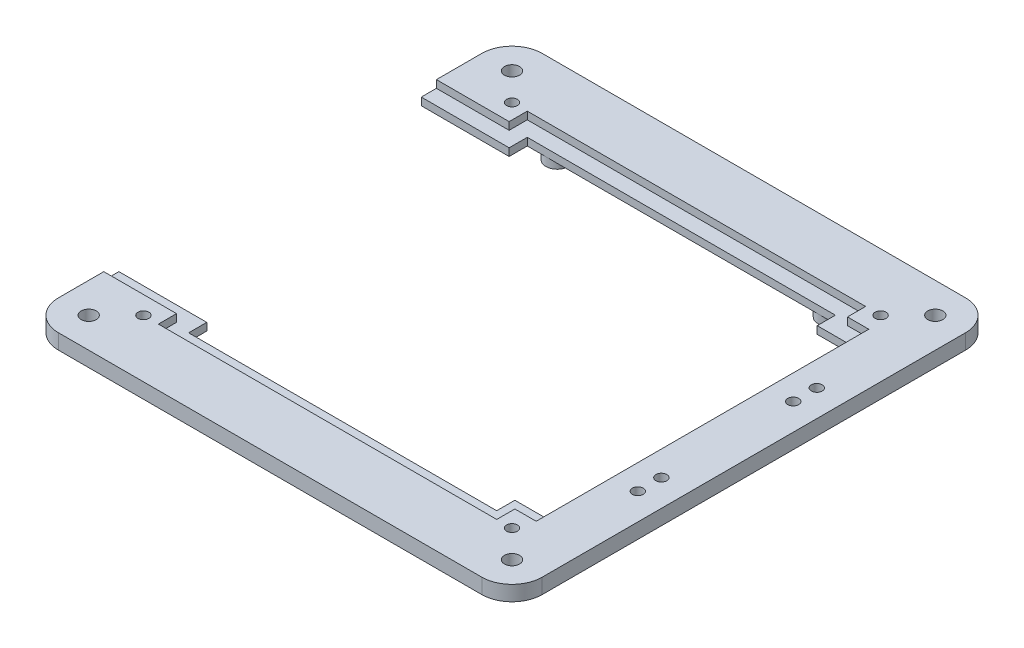
from build123d import *

# Parameters (mm, degrees)
BOSS_EXTRUDE2_DEPTH = 6.35
SKETCH2_R           = 3.175
CUT_EXTRUDE1_DEPTH  = 7.35
SKETCH7_R           = 2.286
CUT_EXTRUDE3_DEPTH  = 12.7
SKETCH8_R           = 2.286
CUT_EXTRUDE4_DEPTH  = 7.35
SKETCH9_W           = 129.404437756
SKETCH9_H           = 7.62
CUT_EXTRUDE5_DEPTH  = 7.35
SKETCH10_R          = 4.826
SKETCH10_R_2        = 2.286
BOSS_EXTRUDE3_DEPTH = 3.81
CUT_EXTRUDE6_DEPTH  = 3.175


with BuildPart() as part:
    # Sketch1 → Boss-Extrude2 (new body)
    with BuildSketch(Plane(origin=(0, 0, 0), x_dir=(1, 0, 0), z_dir=(0, 1, 0))):
        with BuildLine():
            Line((0, 0), (0, 25.4))
            ThreePointArc((0, 25.4), (3.719743879, 34.380256121), (12.7, 38.1))
            Line((12.7, 38.1), (190.5, 38.1))
            ThreePointArc((190.5, 38.1), (199.480256121, 34.380256121), (203.2, 25.4))
            Line((203.2, 25.4), (203.2, -152.4))
            ThreePointArc((203.2, -152.4), (199.480256121, -161.380256121), (190.5, -165.1))
            Line((190.5, -165.1), (12.7, -165.1))
            ThreePointArc((12.7, -165.1), (3.719743879, -161.380256121), (0, -152.4))
            Line((0, -152.4), (0, -127))
            Line((0, -127), (181.61, -127))
            Line((181.61, -127), (181.61, 0))
            Line((181.61, 0), (0, 0))
        make_face()
    extrude(amount=BOSS_EXTRUDE2_DEPTH)

    # Sketch2 → Cut-Extrude1 (cut, through all)
    with BuildSketch(Plane(origin=(0, 6.35, 0), x_dir=(1, 0, 0), z_dir=(0, 1, 0))):
        with Locations((12.7, 25.4)):
            Circle(SKETCH2_R)
        with Locations((190.5, 25.4)):
            Circle(SKETCH2_R)
        with Locations((190.5, -152.4)):
            Circle(SKETCH2_R)
        with Locations((12.7, -152.4)):
            Circle(SKETCH2_R)
    extrude(amount=-CUT_EXTRUDE1_DEPTH, mode=Mode.SUBTRACT)

    # Sketch7 → Cut-Extrude3 (cut)
    with BuildSketch(Plane(origin=(0, 6.35, 0), x_dir=(1, 0, 0), z_dir=(0, 1, 0))):
        with Locations((192.024, -101.092)):
            Circle(SKETCH7_R)
        with Locations((192.024, -91.186)):
            Circle(SKETCH7_R)
        with Locations((192.024, -35.814)):
            Circle(SKETCH7_R)
        with Locations((192.024, -25.908)):
            Circle(SKETCH7_R)
    extrude(amount=-CUT_EXTRUDE3_DEPTH, mode=Mode.SUBTRACT)

    # Sketch8 → Cut-Extrude4 (cut, through all)
    with BuildSketch(Plane(origin=(0, 0, 0), x_dir=(-1, 0, 0), z_dir=(0, -1, 0))):
        with Locations((-24.197781122, 13.902218878)):
            Circle(SKETCH8_R)
        with Locations((-24.197781122, -140.902218878)):
            Circle(SKETCH8_R)
        with Locations((-179.002218878, -140.902218878)):
            Circle(SKETCH8_R)
        with Locations((-179.002218878, 13.902218878)):
            Circle(SKETCH8_R)
    extrude(amount=-CUT_EXTRUDE4_DEPTH, mode=Mode.SUBTRACT)

    # Sketch9 → Cut-Extrude5 (cut, through all)
    with BuildSketch(Plane(origin=(0, 6.35, 0), x_dir=(1, 0, 0), z_dir=(0, 1, 0))):
        with Locations((101.6, 3.81)):
            Rectangle(SKETCH9_W, SKETCH9_H)
        with Locations((101.6, -130.81)):
            Rectangle(SKETCH9_W, SKETCH9_H)
    extrude(amount=-CUT_EXTRUDE5_DEPTH, mode=Mode.SUBTRACT)

    # Sketch10 → Boss-Extrude3 (add)
    with BuildSketch(Plane(origin=(0, 0, 0), x_dir=(-1, 0, 0), z_dir=(0, -1, 0))):
        with Locations((-44.45, 12.7)):
            Circle(SKETCH10_R)
        with Locations((-44.45, 12.7)):
            Circle(SKETCH10_R_2, mode=Mode.SUBTRACT)
        with Locations((-158.75, 12.7)):
            Circle(SKETCH10_R)
        with Locations((-158.75, 12.7)):
            Circle(SKETCH10_R_2, mode=Mode.SUBTRACT)
        with Locations((-158.75, -139.7)):
            Circle(SKETCH10_R)
        with Locations((-158.75, -139.7)):
            Circle(SKETCH10_R_2, mode=Mode.SUBTRACT)
        with Locations((-44.45, -139.7)):
            Circle(SKETCH10_R)
        with Locations((-44.45, -139.7)):
            Circle(SKETCH10_R_2, mode=Mode.SUBTRACT)
    extrude(amount=BOSS_EXTRUDE3_DEPTH)

    # Sketch11 → Cut-Extrude6 (cut)
    with BuildSketch(Plane(origin=(0, 6.35, 0), x_dir=(1, 0, 0), z_dir=(0, 1, 0))):
        Polygon((0, 0), (36.897781122, 0), (36.897781122, 7.62), (166.302218878, 7.62), (166.302218878, 0), (181.61, 0), (181.61, 6.35), (172.652218878, 6.35), (172.652218878, 13.97), (30.547781122, 13.97), (30.547781122, 6.35), (0, 6.35), align=None)
        Polygon((0, -133.35), (0, -127), (36.897781122, -127), (36.897781122, -134.62), (166.302218878, -134.62), (166.302218878, -127), (181.61, -127), (181.61, -133.35), (172.652218878, -133.35), (172.652218878, -140.97), (30.547781122, -140.97), (30.547781122, -133.35), align=None)
    extrude(amount=-CUT_EXTRUDE6_DEPTH, mode=Mode.SUBTRACT)


solid = part.part
